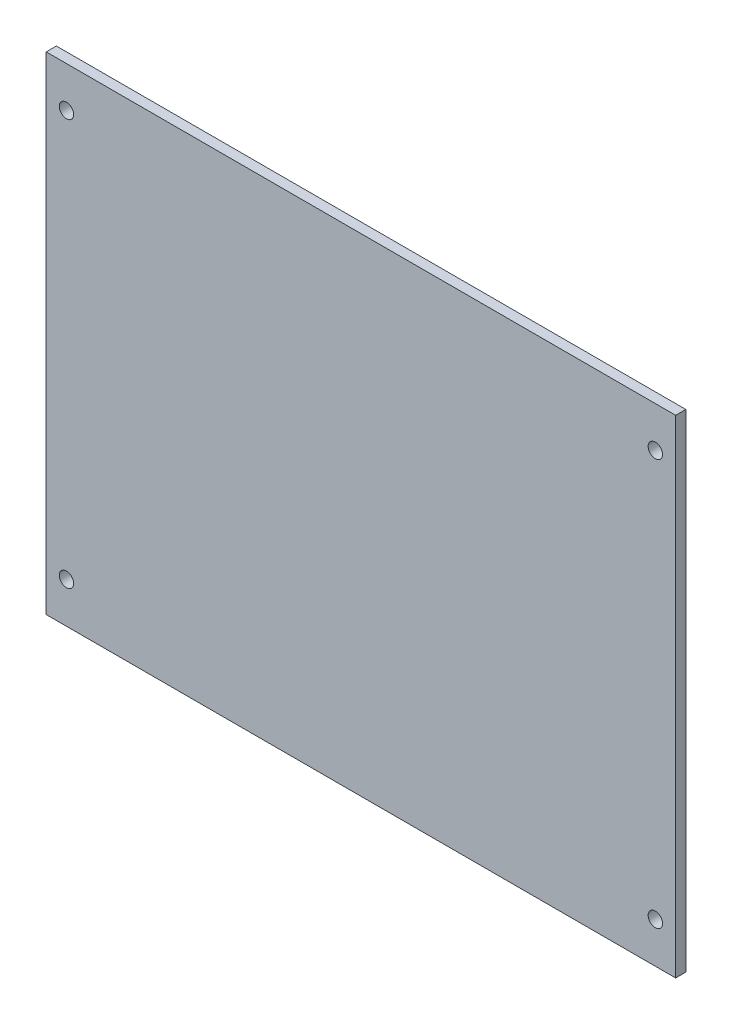
from build123d import *

# Parameters (mm, degrees)
SKETCH1_W           = 196.85
SKETCH1_H           = 152.4
SKETCH1_R           = 2.25
BOSS_EXTRUDE1_DEPTH = 3.175


with BuildPart() as part:
    # Sketch1 → Boss-Extrude1 (new body)
    with BuildSketch(Plane.XY):
        Rectangle(SKETCH1_W, SKETCH1_H)
        with Locations((-92.075, 63.5)):
            Circle(SKETCH1_R, mode=Mode.SUBTRACT)
        with Locations((92.075, 63.5)):
            Circle(SKETCH1_R, mode=Mode.SUBTRACT)
        with Locations((92.075, -63.5)):
            Circle(SKETCH1_R, mode=Mode.SUBTRACT)
        with Locations((-92.075, -63.5)):
            Circle(SKETCH1_R, mode=Mode.SUBTRACT)
    extrude(amount=BOSS_EXTRUDE1_DEPTH)


solid = part.part
